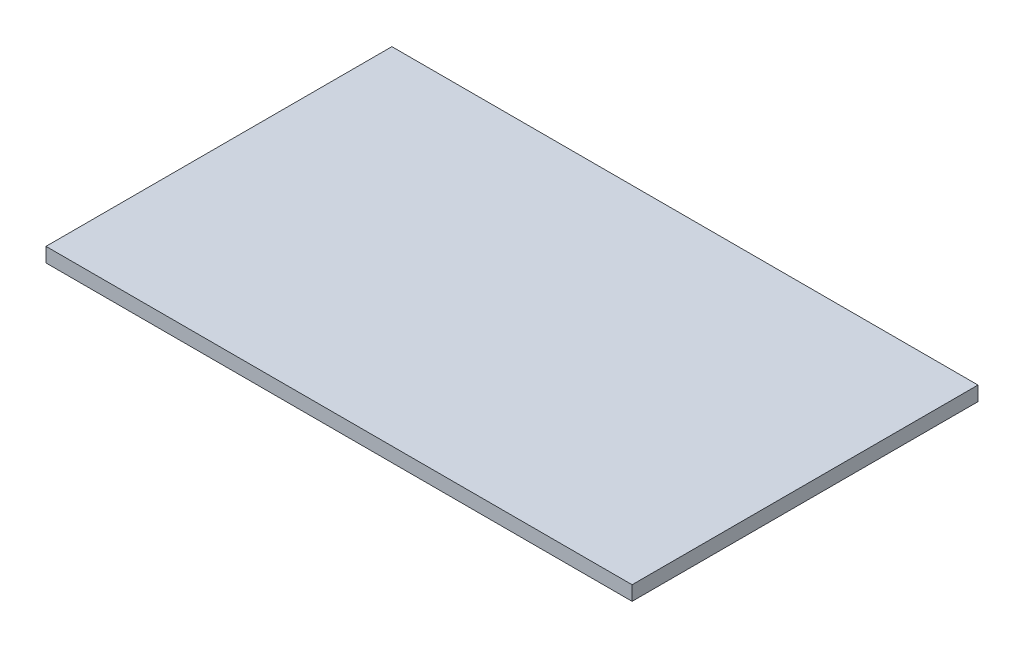
from build123d import *

# Parameters (mm, degrees)
SKETCH1_W           = 610
SKETCH1_H           = 360
BOSS_EXTRUDE1_DEPTH = 15


with BuildPart() as part:
    # Sketch1 → Boss-Extrude1 (new body)
    with BuildSketch(Plane(origin=(0, 0, 0), x_dir=(1, 0, 0), z_dir=(0, 1, 0))):
        with Locations((258.73392535, -152.357980823)):
            Rectangle(SKETCH1_W, SKETCH1_H)
    extrude(amount=BOSS_EXTRUDE1_DEPTH)


solid = part.part
